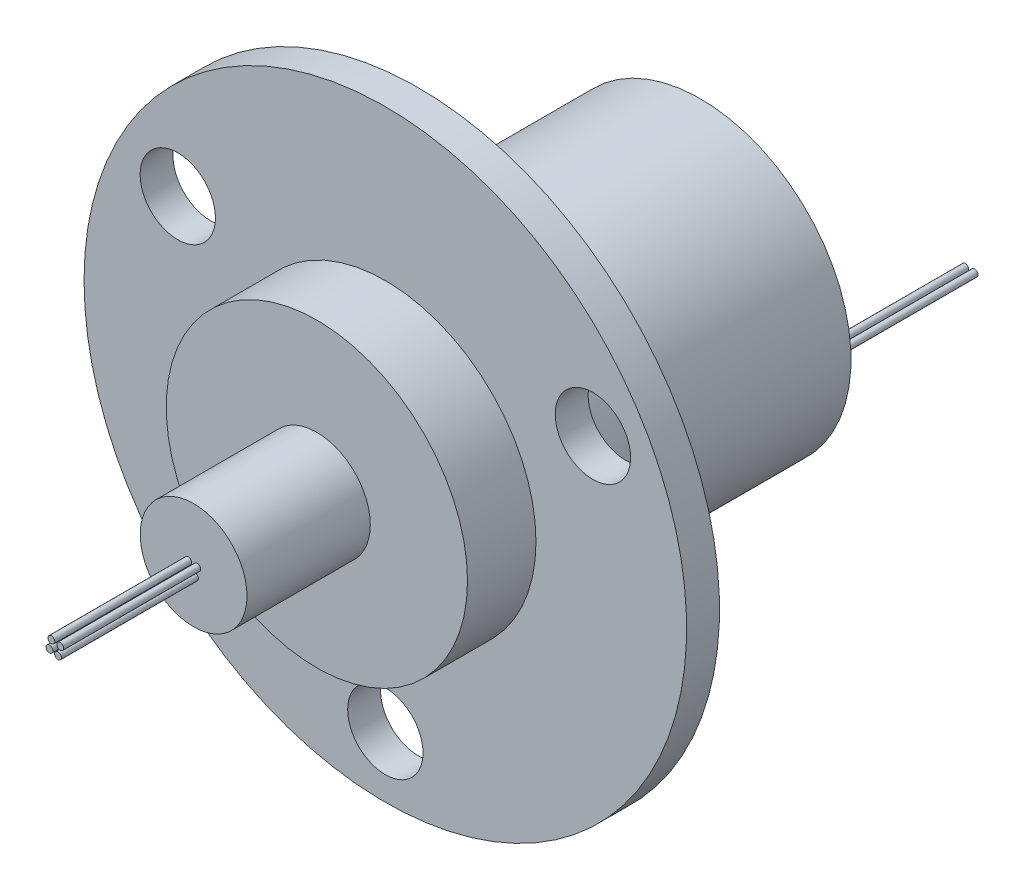
from build123d import *

# Parameters (mm, degrees)
SKETCH1_W                      = 22
SKETCH1_H                      = 2.4
SKETCH2_R                      = 11
BOSS_EXTRUDE1_DEPTH            = 5
SKETCH3_R                      = 3.9
BOSS_EXTRUDE2_DEPTH            = 9
SKETCH4_R                      = 11
BOSS_EXTRUDE3_DEPTH            = 20.6
SKETCH5_W                      = 0.25
SKETCH5_H                      = 10
SKETCH6_W                      = 0.25
SKETCH6_H                      = 10
SKETCH7_W                      = 0.25
SKETCH7_H                      = 10
SKETCH8_W                      = 0.25
SKETCH8_H                      = 10
SKETCH9_W                      = 0.25
SKETCH9_H                      = 10
SKETCH10_W                     = 0.25
SKETCH10_H                     = 10
SKETCH11_W                     = 0.25
SKETCH11_H                     = 10
SKETCH12_W                     = 0.25
SKETCH12_H                     = 10
F_5_5_5_5_DIAMETER_HOLE1_D     = 5.5
F_5_5_5_5_DIAMETER_HOLE1_DEPTH = 26.4


with BuildPart() as part:
    # Sketch1 → Revolve1 (revolve)
    with BuildSketch(Plane.XZ):
        with Locations((11, 1.2)):
            Rectangle(SKETCH1_W, SKETCH1_H)
    revolve(axis=Axis((0, 0, 2.4), (0, 0, -1)))

    # Sketch2 → Boss-Extrude1 (add)
    with BuildSketch(Plane.XY.offset(2.4)):
        Circle(SKETCH2_R)
    extrude(amount=BOSS_EXTRUDE1_DEPTH)

    # Sketch3 → Boss-Extrude2 (add)
    with BuildSketch(Plane.XY.offset(7.4)):
        Circle(SKETCH3_R)
    extrude(amount=BOSS_EXTRUDE2_DEPTH)

    # Sketch4 → Boss-Extrude3 (add)
    with BuildSketch(Plane(origin=(0, 0, 0), x_dir=(-1, 0, 0), z_dir=(0, 0, -1))):
        Circle(SKETCH4_R)
    extrude(amount=BOSS_EXTRUDE3_DEPTH)

    # Sketch5 → Revolve2 (revolve)
    with BuildSketch(Plane.XZ.offset(0.675788748)):
        with Locations((0.22311943, 21.4)):
            Rectangle(SKETCH5_W, SKETCH5_H)
    revolve(axis=Axis((0.09811943, -0.675788748, 26.4), (0, 0, -1)))

    # Sketch6 → Revolve3 (revolve)
    with BuildSketch(Plane.XZ.offset(-0.091161083)):
        with Locations((-0.260169312, 21.4)):
            Rectangle(SKETCH6_W, SKETCH6_H)
    revolve(axis=Axis((-0.385169312, 0.091161083, 26.4), (0, 0, -1)))

    # Sketch7 → Revolve4 (revolve)
    with BuildSketch(Plane.XZ.offset(0.562471217)):
        with Locations((-0.402355812, 21.4)):
            Rectangle(SKETCH7_W, SKETCH7_H)
    revolve(axis=Axis((-0.527355812, -0.562471217, 26.4), (0, 0, -1)))

    # Sketch8 → Revolve5 (revolve)
    with BuildSketch(Plane(origin=(0, 0, 0), x_dir=(1, 0, 0), z_dir=(0, 1, 0))):
        with Locations((-9.138912968, 25.6)):
            Rectangle(SKETCH8_W, SKETCH8_H)
    revolve(axis=Axis((-9.263912968, 0, -30.6), (0, 0, 1)))

    # Sketch9 → Revolve6 (revolve)
    with BuildSketch(Plane(origin=(0, 0, 0), x_dir=(1, 0, 0), z_dir=(0, 1, 0))):
        with Locations((10.149169803, 25.6)):
            Rectangle(SKETCH9_W, SKETCH9_H)
    revolve(axis=Axis((10.024169803, 0, -30.6), (0, 0, 1)))

    # Sketch10 → Revolve7 (revolve)
    with BuildSketch(Plane(origin=(0, 0, 0), x_dir=(1, 0, 0), z_dir=(0, 1, 0))):
        with Locations((9.469293537, 25.6)):
            Rectangle(SKETCH10_W, SKETCH10_H)
    revolve(axis=Axis((9.344293537, 0, -30.6), (0, 0, 1)))

    # Sketch11 → Revolve8 (revolve)
    with BuildSketch(Plane(origin=(0, 0, 0), x_dir=(1, 0, 0), z_dir=(0, 1, 0))):
        with Locations((-9.977336314, 25.6)):
            Rectangle(SKETCH11_W, SKETCH11_H)
    revolve(axis=Axis((-10.102336314, 0, -30.6), (0, 0, 1)))

    # Sketch12 → Revolve9 (revolve)
    with BuildSketch(Plane.XZ):
        with Locations((0.388776295, 21.4)):
            Rectangle(SKETCH12_W, SKETCH12_H)
    revolve(axis=Axis((0.263776295, 0, 26.4), (0, 0, -1)))

    # Ø5.5 (5.5) Diameter Hole1
    with Locations(Plane(origin=(0, 0, 0), x_dir=(-1, 0, 0), z_dir=(0, 0, -1))):
        with Locations((-15.155444566, 8.75), (15.155444566, 8.75), (0, -17.5)):
            Hole(F_5_5_5_5_DIAMETER_HOLE1_D / 2, depth=F_5_5_5_5_DIAMETER_HOLE1_DEPTH)


solid = part.part
